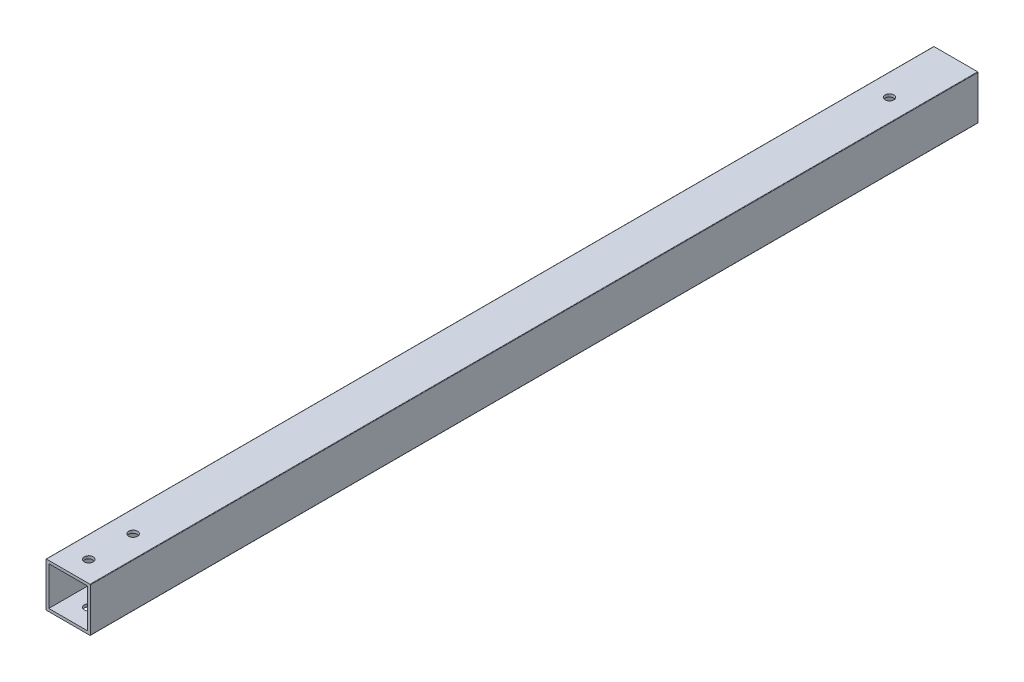
from build123d import *

# Parameters (mm, degrees)
SKETCH1_W           = 22.225
SKETCH1_H           = 22.225
BOSS_EXTRUDE1_DEPTH = 508
SKETCH7_R           = 2.54
CUT_EXTRUDE5_DEPTH  = 26.4
SKETCH8_R           = 2.4892
CUT_EXTRUDE6_DEPTH  = 25.4


with BuildPart() as part:
    # Sketch1 → Boss-Extrude1 (new body)
    with BuildSketch(Plane(origin=(0, 0, 0), x_dir=(-1, 0, 0), z_dir=(0, 0, -1))):
        with BuildLine():
            Line((1.5875, -1.3335), (1.5875, 23.5585))
            ThreePointArc((1.5875, 23.5585), (1.513105122, 23.738105122), (1.3335, 23.8125))
            Line((1.3335, 23.8125), (-23.5585, 23.8125))
            ThreePointArc((-23.5585, 23.8125), (-23.738105122, 23.738105122), (-23.8125, 23.5585))
            Line((-23.8125, 23.5585), (-23.8125, -1.3335))
            ThreePointArc((-23.8125, -1.3335), (-23.738105122, -1.513105122), (-23.5585, -1.5875))
            Line((-23.5585, -1.5875), (1.3335, -1.5875))
            ThreePointArc((1.3335, -1.5875), (1.513105122, -1.513105122), (1.5875, -1.3335))
        make_face()
        with Locations((-11.1125, 11.1125)):
            Rectangle(SKETCH1_W, SKETCH1_H, mode=Mode.SUBTRACT)
    extrude(amount=-BOSS_EXTRUDE1_DEPTH)

    # Sketch7 → Cut-Extrude5 (cut, through all)
    with BuildSketch(Plane.XZ.offset(1.5875)):
        with Locations((10.9125, 470.65)):
            Circle(SKETCH7_R)
        with Locations((10.9125, 496.05)):
            Circle(SKETCH7_R)
    extrude(amount=-CUT_EXTRUDE5_DEPTH, mode=Mode.SUBTRACT)

    # Sketch8 → Cut-Extrude6 (cut)
    with BuildSketch(Plane(origin=(0, 23.8125, 0), x_dir=(1, 0, 0), z_dir=(0, 1, 0))):
        with Locations((11.1125, -37.933268304)):
            Circle(SKETCH8_R)
    extrude(amount=-CUT_EXTRUDE6_DEPTH, mode=Mode.SUBTRACT)


solid = part.part
